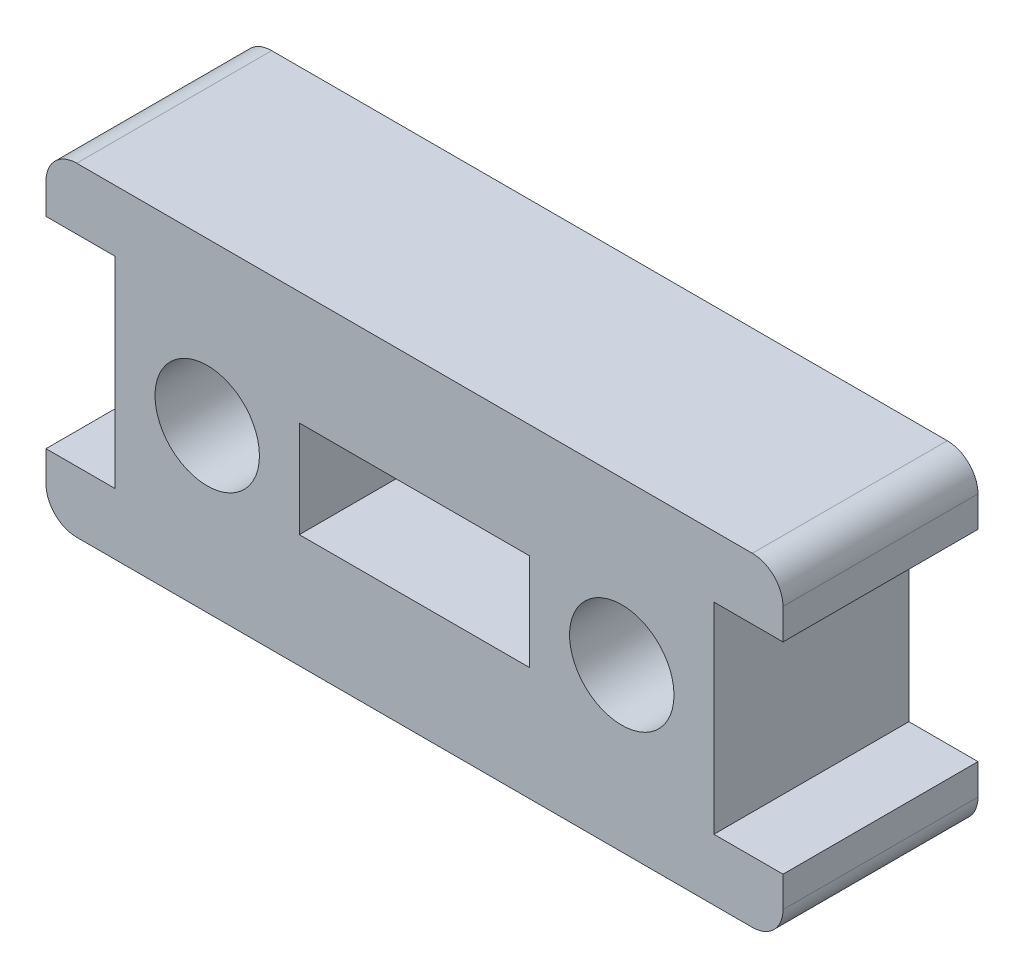
from build123d import *

# Parameters (mm, degrees)
SKETCH1_W            = 7.5
SKETCH1_H            = 3.15
BOSS_EXTRUDE1_DEPTH  = 6.35
M3_CLEARANCE_HOLE1_D = 3.4
FILLET1_R            = 1


with BuildPart() as part:
    # Sketch1 → Boss-Extrude1 (new body)
    with BuildSketch(Plane.XY):
        Polygon((-12, 3.275), (-9.75, 3.275), (-9.75, -3.275), (-12, -3.275), (-12, -5.275), (12, -5.275), (12, -3.275), (9.75, -3.275), (9.75, 3.275), (12, 3.275), (12, 5.275), (-12, 5.275), align=None)
        Rectangle(SKETCH1_W, SKETCH1_H, mode=Mode.SUBTRACT)
    extrude(amount=BOSS_EXTRUDE1_DEPTH)

    # M3 Clearance Hole1 (through all)
    with Locations(Plane.XY.offset(6.35)):
        with Locations((-6.75, 0), (6.75, 0)):
            Hole(M3_CLEARANCE_HOLE1_D / 2)

    # Fillet1
    fillet1_edges = [part.edges().sort_by_distance(p)[0] for p in [
        (-12, 5.275, 3.175),
        (12, 5.275, 3.175),
        (12, -5.275, 3.175),
        (-12, -5.275, 3.175),
    ]]
    fillet(fillet1_edges, radius=FILLET1_R)


solid = part.part
